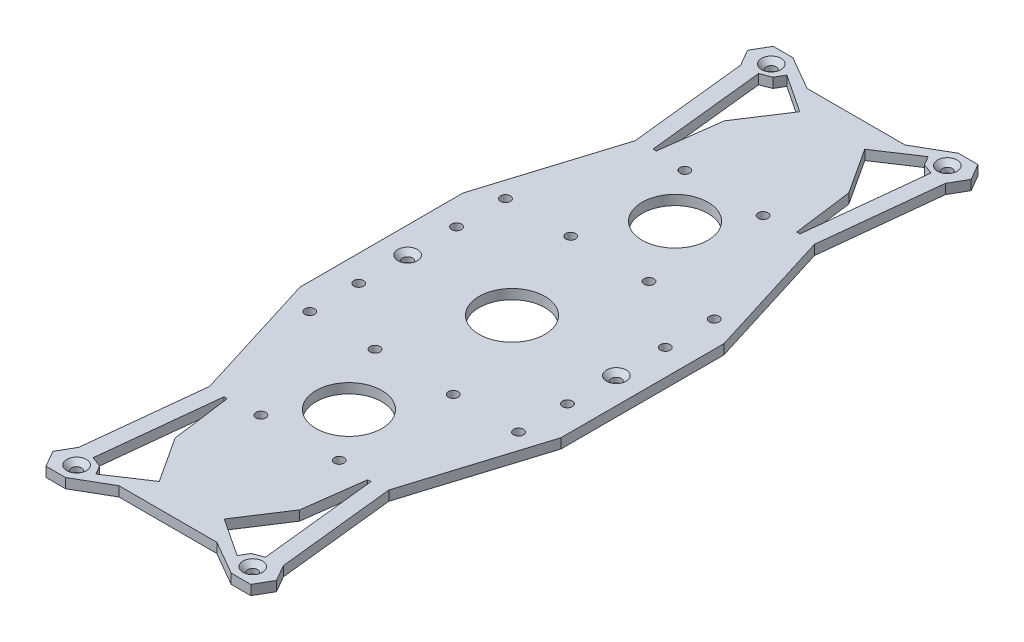
from build123d import *

# Parameters (mm, degrees)
SKETCH_1_W                   = 80
SKETCH_1_H                   = 50
EXTRUDE_1_DEPTH              = 3
EXTRUDE_2_DEPTH              = 3
SKETCH_8_R                   = 1.5
CUT_EXTRUDE_4_DEPTH          = 3
CUT_EXTRUDE_START            = -4
CUT_EXTRUDE_6_DEPTH          = 5
HOLE_WIZARD_M3_1_D           = 3
HOLE_WIZARD_M3_1_CSINK_D     = 6
HOLE_WIZARD_M3_1_CSINK_ANGLE = 90
MIRROR_7_COPY_1_DEPTH        = 3
MIRROR_START                 = -4
MIRROR_7_COPY_2_DEPTH        = 5
MIRROR_7_COPY_3_D            = 3
MIRROR_7_COPY_3_CSINK_D      = 6
MIRROR_7_COPY_3_CSINK_ANGLE  = 90
SKETCH_14_R                  = 10.1
CUT_EXTRUDE_7_DEPTH          = 4
SKETCH_15_R                  = 1.5
CUT_EXTRUDE_8_DEPTH          = 10
MIRROR_9_COPY_1_SKETCH_R     = 1.5
MIRROR_9_COPY_1_DEPTH        = 10


with BuildPart() as part:
    # 草图1 → 凸台-拉伸1 (new body)
    with BuildSketch(Plane(origin=(0, 0, 0), x_dir=(1, 0, 0), z_dir=(0, 1, 0))):
        Polygon((-15, -105.5), (-40, -25), (40, -25), (15, -105.5), align=None)
        Rectangle(SKETCH_1_W, SKETCH_1_H)
        Polygon((-15, 105.5), (15, 105.5), (40, 25), (-40, 25), align=None)
    extrude(amount=EXTRUDE_1_DEPTH)

    # 草图7 → 凸台-拉伸2 (add)
    with BuildSketch(Plane(origin=(0, 3, 0), x_dir=(1, 0, 0), z_dir=(0, 1, 0))):
        Polygon((15, 105.5), (25.392304845, 111.5), (31.392304845, 111.5), (34.279056191, 106.5), (31.392304845, 101.5), (27.5, 65.25), align=None)
    extrude_2 = extrude(amount=-EXTRUDE_2_DEPTH)

    # 草图8 → 切除-拉伸4 (cut)
    with BuildSketch(Plane(origin=(0, 3, 0), x_dir=(1, 0, 0), z_dir=(0, 1, 0))):
        with Locations((27, 106.5)):
            Circle(SKETCH_8_R)
    extrude(amount=-CUT_EXTRUDE_4_DEPTH, mode=Mode.SUBTRACT)

    # 草图9 → 切除-拉伸6 (cut)
    with BuildSketch(Plane(origin=(0, 3, 0), x_dir=(1, 0, 0), z_dir=(0, 1, 0)).offset(CUT_EXTRUDE_START)):
        Polygon((22.528576043, 65.783801312), (26.420880888, 102.033801312), (23.243297221, 103.222190391), (21.66924243, 105.948533263), (16.658152368, 102.627995852), (19.093364206, 84.205898582), (21.528576043, 65.783801312), align=None)
        Polygon((10.313400805, 97.671116845), (19.093364206, 84.205898582), (16.658152368, 102.627995852), (9.970725358, 98.196654308), align=None)
    cut_extrude_6 = extrude(amount=CUT_EXTRUDE_6_DEPTH, mode=Mode.SUBTRACT)

    # M3 六角凹锥坑螺钉的锥形沉头孔1 (through all)
    with Locations(Plane(origin=(0, 3, 0), x_dir=(1, 0, 0), z_dir=(0, 1, 0))):
        with Locations((27, 106.5), (32, 0)):
            hole_wizard_m3_1 = CounterSinkHole(HOLE_WIZARD_M3_1_D / 2, HOLE_WIZARD_M3_1_CSINK_D / 2, counter_sink_angle=HOLE_WIZARD_M3_1_CSINK_ANGLE)

    # 镜向5: M3 六角凹锥坑螺钉的锥形沉头孔1 across plane
    add(hole_wizard_m3_1.mirror(Plane(origin=(0, 0, 0), x_dir=(0, 0, 1), z_dir=(1, 0, 0))), mode=Mode.SUBTRACT)

    # 镜向6: 凸台-拉伸2, 切除-拉伸6, M3 六角凹锥坑螺钉的锥形沉头孔1 across plane
    add(extrude_2.mirror(Plane(origin=(0, 0, 0), x_dir=(0, 0, 1), z_dir=(1, 0, 0))))
    add(cut_extrude_6.mirror(Plane(origin=(0, 0, 0), x_dir=(0, 0, 1), z_dir=(1, 0, 0))), mode=Mode.SUBTRACT)
    add(hole_wizard_m3_1.mirror(Plane(origin=(0, 0, 0), x_dir=(0, 0, 1), z_dir=(1, 0, 0))), mode=Mode.SUBTRACT)

    # 镜向7: 凸台-拉伸2, 切除-拉伸6, M3 六角凹锥坑螺钉的锥形沉头孔1 across plane
    add(extrude_2.mirror(Plane.XY))
    add(cut_extrude_6.mirror(Plane.XY), mode=Mode.SUBTRACT)
    add(hole_wizard_m3_1.mirror(Plane.XY), mode=Mode.SUBTRACT)

    # 镜向7 copy 1 sketch → 镜向7 copy 1 (add)
    with BuildSketch(Plane(origin=(0, 3, 0), x_dir=(-1, 0, 0), z_dir=(0, 1, 0))):
        Polygon((15, 105.5), (25.392304845, 111.5), (31.392304845, 111.5), (34.279056191, 106.5), (31.392304845, 101.5), (27.5, 65.25), align=None)
    extrude(amount=-MIRROR_7_COPY_1_DEPTH)

    # 镜向7 copy 2 sketch → 镜向7 copy 2 (cut)
    with BuildSketch(Plane(origin=(0, 3, 0), x_dir=(-1, 0, 0), z_dir=(0, 1, 0)).offset(MIRROR_START)):
        Polygon((22.528576043, 65.783801312), (26.420880888, 102.033801312), (23.243297221, 103.222190391), (21.66924243, 105.948533263), (16.658152368, 102.627995852), (19.093364206, 84.205898582), (21.528576043, 65.783801312), align=None)
        Polygon((10.313400805, 97.671116845), (19.093364206, 84.205898582), (16.658152368, 102.627995852), (9.970725358, 98.196654308), align=None)
    extrude(amount=MIRROR_7_COPY_2_DEPTH, mode=Mode.SUBTRACT)

    # 镜向7 copy 3 (through all)
    with Locations(Plane(origin=(0, 3, 0), x_dir=(-1, 0, 0), z_dir=(0, 1, 0))):
        with Locations((27, 106.5), (32, 0)):
            CounterSinkHole(MIRROR_7_COPY_3_D / 2, MIRROR_7_COPY_3_CSINK_D / 2, counter_sink_angle=MIRROR_7_COPY_3_CSINK_ANGLE)

    # 草图14 → 切除-拉伸7 (cut, through all)
    with BuildSketch(Plane(origin=(0, 3, 0), x_dir=(1, 0, 0), z_dir=(0, 1, 0))):
        Circle(SKETCH_14_R)
        with Locations((0, -50)):
            Circle(SKETCH_14_R)
        with Locations((0, 50)):
            Circle(SKETCH_14_R)
    extrude(amount=-CUT_EXTRUDE_7_DEPTH, mode=Mode.SUBTRACT)

    # 草图15 → 切除-拉伸8 (cut)
    with BuildSketch(Plane.XZ):
        with Locations((-32, 15)):
            Circle(SKETCH_15_R)
        with Locations((-32, 30)):
            Circle(SKETCH_15_R)
        with Locations((-12, 65)):
            Circle(SKETCH_15_R)
        with Locations((-12, 30)):
            Circle(SKETCH_15_R)
    cut_extrude_8 = extrude(amount=-CUT_EXTRUDE_8_DEPTH, mode=Mode.SUBTRACT)

    # 镜向8: 切除-拉伸8 across plane
    add(cut_extrude_8.mirror(Plane(origin=(0, 0, 0), x_dir=(0, 0, 1), z_dir=(1, 0, 0))), mode=Mode.SUBTRACT)

    # 镜向9: 切除-拉伸8 across plane
    add(cut_extrude_8.mirror(Plane.XY), mode=Mode.SUBTRACT)

    # 镜向9 copy 1 sketch → 镜向9 copy 1 (cut)
    with BuildSketch(Plane(origin=(0, 0, 0), x_dir=(-1, 0, 0), z_dir=(0, -1, 0))):
        with Locations((-32, 15)):
            Circle(MIRROR_9_COPY_1_SKETCH_R)
        with Locations((-32, 30)):
            Circle(MIRROR_9_COPY_1_SKETCH_R)
        with Locations((-12, 65)):
            Circle(MIRROR_9_COPY_1_SKETCH_R)
        with Locations((-12, 30)):
            Circle(MIRROR_9_COPY_1_SKETCH_R)
    extrude(amount=-MIRROR_9_COPY_1_DEPTH, mode=Mode.SUBTRACT)


solid = part.part
